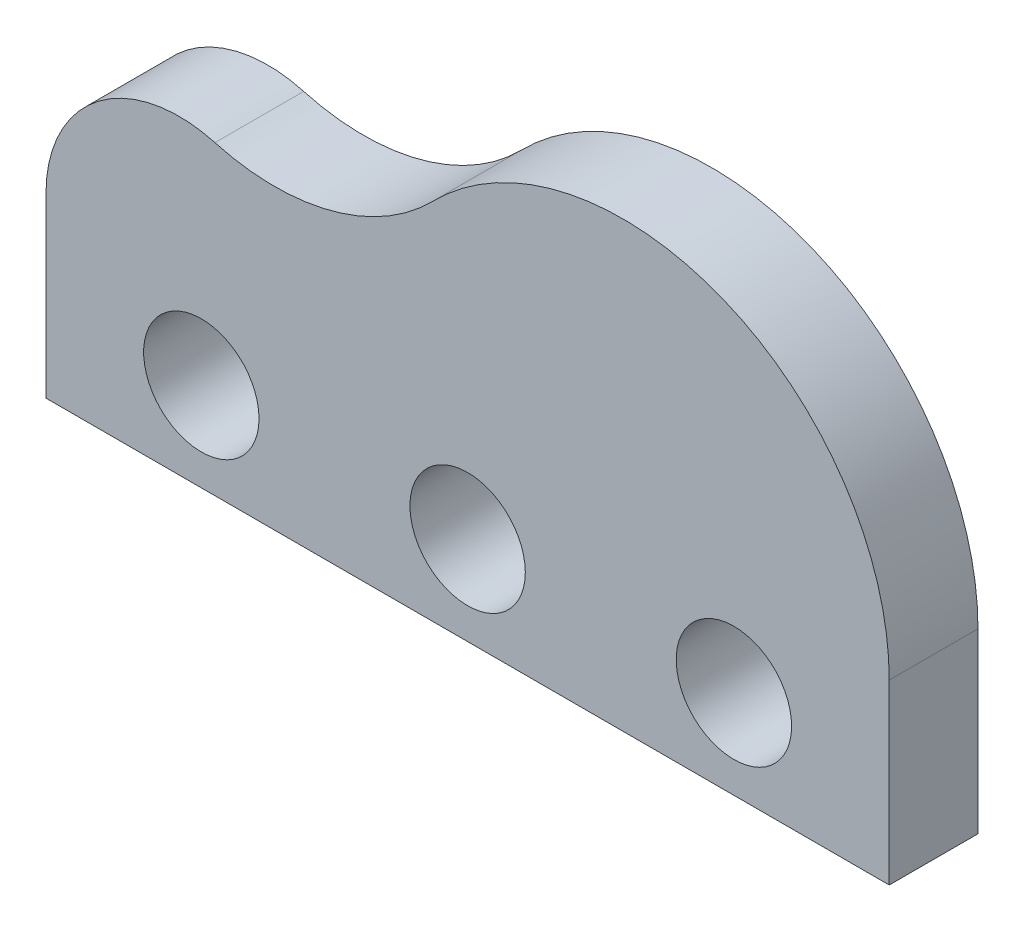
from build123d import *

# Parameters (mm, degrees)
SKETCH1_R           = 6.5
BOSS_EXTRUDE1_DEPTH = 5


with BuildPart() as part:
    # Sketch1 → Boss-Extrude1 (new body, symmetric)
    with BuildSketch(Plane.XY):
        with BuildLine():
            Line((0, 20), (0, 0))
            Line((0, 0), (95, 0))
            Line((95, 0), (95, 20))
            ThreePointArc((95, 20), (76.35181203, 47.769342153), (43.590909091, 41.015490155))
            ThreePointArc((43.590909091, 41.015490155), (32.208180594, 34.376961736), (19.03125, 34.448149481))
            ThreePointArc((19.03125, 34.448149481), (5.929960033, 31.947149242), (0, 20))
        make_face()
        with Locations((17.5, 10)):
            Circle(SKETCH1_R, mode=Mode.SUBTRACT)
        with Locations((47.5, 10)):
            Circle(SKETCH1_R, mode=Mode.SUBTRACT)
        with Locations((77.5, 10)):
            Circle(SKETCH1_R, mode=Mode.SUBTRACT)
    extrude(amount=BOSS_EXTRUDE1_DEPTH, both=True)


solid = part.part
